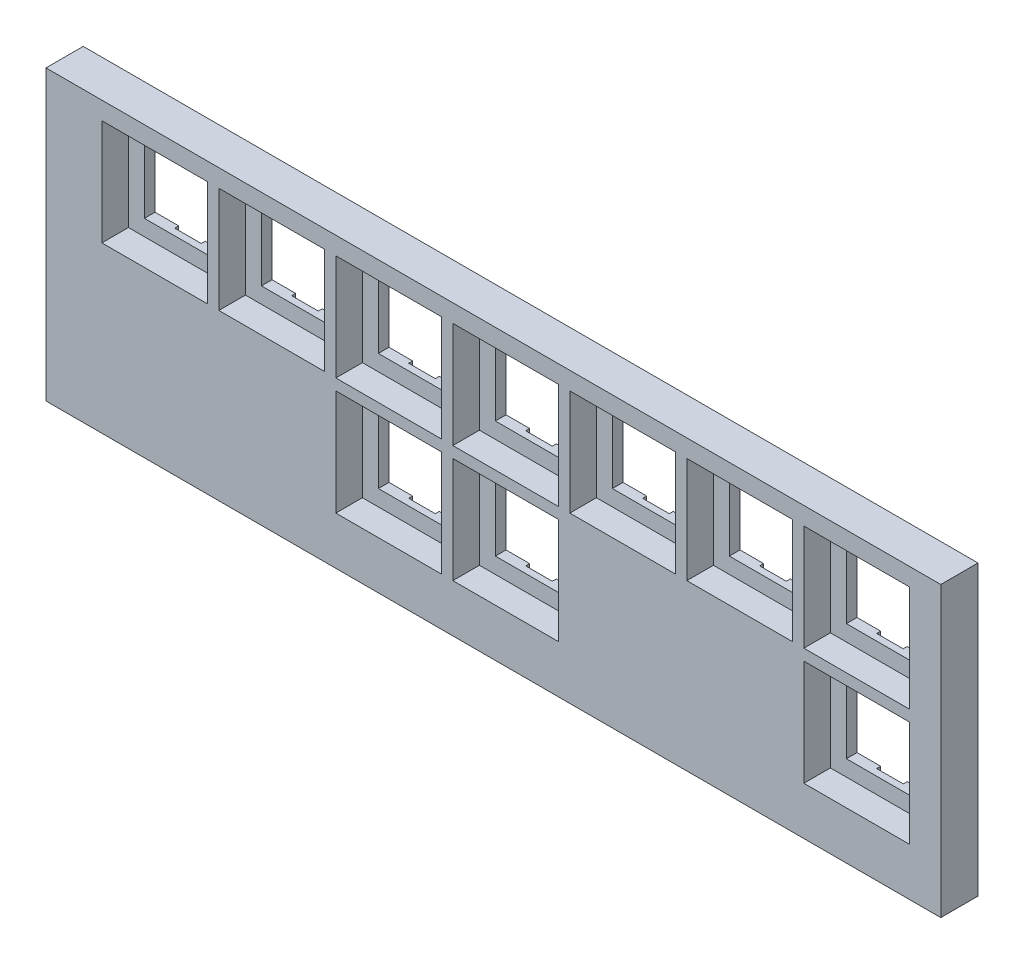
from build123d import *

# Parameters (mm, degrees)
SKETCH6_W                 = 168.25
SKETCH6_H                 = 54.25
BOSS_EXTRUDE2_DEPTH       = 7
SKETCH7_W                 = 19.9
SKETCH7_H                 = 19.9
CUT_EXTRUDE4_DEPTH        = 5
SKETCH8_W                 = 13.9
SKETCH8_H                 = 13.9
CUT_EXTRUDE5_DEPTH        = 4
SKETCH9_W                 = 5
SKETCH9_H                 = 0.75
CUT_EXTRUDE6_DEPTH        = 1
LPATTERN1_COUNT           = 7
LPATTERN1_PITCH           = 22
LPATTERN1_COUNT_DIR2      = 2
LPATTERN1_PITCH_DIR2      = 22
LPATTERN1_COPY_1_SKETCH_W = 5
LPATTERN1_COPY_1_SKETCH_H = 0.75
LPATTERN1_COPY_1_DEPTH    = 1
LPATTERN1_COPY_2_SKETCH_W = 5
LPATTERN1_COPY_2_SKETCH_H = 0.75
LPATTERN1_COPY_2_DEPTH    = 1
LPATTERN1_COPY_3_SKETCH_W = 5
LPATTERN1_COPY_3_SKETCH_H = 0.75
LPATTERN1_COPY_3_DEPTH    = 1
LPATTERN1_COPY_4_SKETCH_W = 5
LPATTERN1_COPY_4_SKETCH_H = 0.75
LPATTERN1_COPY_4_DEPTH    = 1
LPATTERN1_COPY_5_SKETCH_W = 5
LPATTERN1_COPY_5_SKETCH_H = 0.75
LPATTERN1_COPY_5_DEPTH    = 1
LPATTERN1_COPY_6_SKETCH_W = 5
LPATTERN1_COPY_6_SKETCH_H = 0.75
LPATTERN1_COPY_6_DEPTH    = 1
LPATTERN1_COPY_7_SKETCH_W = 5
LPATTERN1_COPY_7_SKETCH_H = 0.75
LPATTERN1_COPY_7_DEPTH    = 1
LPATTERN1_COPY_8_SKETCH_W = 5
LPATTERN1_COPY_8_SKETCH_H = 0.75
LPATTERN1_COPY_8_DEPTH    = 1
LPATTERN1_COPY_9_SKETCH_W = 5
LPATTERN1_COPY_9_SKETCH_H = 0.75
LPATTERN1_COPY_9_DEPTH    = 1


with BuildPart() as part:
    # Sketch6 → Boss-Extrude2 (new body)
    with BuildSketch(Plane.XY):
        with Locations((84.125, 27.125)):
            Rectangle(SKETCH6_W, SKETCH6_H)
    extrude(amount=BOSS_EXTRUDE2_DEPTH)

    # Sketch7 → Cut-Extrude4 (cut)
    with BuildSketch(Plane.XY.offset(7)):
        with Locations((20.45, 40.95)):
            Rectangle(SKETCH7_W, SKETCH7_H)
    cut_extrude4 = extrude(amount=-CUT_EXTRUDE4_DEPTH, mode=Mode.SUBTRACT)

    # Sketch8 → Cut-Extrude5 (cut)
    with BuildSketch(Plane.XY.offset(2)):
        with Locations((20.45, 40.95)):
            Rectangle(SKETCH8_W, SKETCH8_H)
    cut_extrude5 = extrude(amount=-CUT_EXTRUDE5_DEPTH, mode=Mode.SUBTRACT)

    # Sketch9 → Cut-Extrude6 (cut)
    with BuildSketch(Plane(origin=(0, 47.9, 0), x_dir=(-1, 0, 0), z_dir=(0, -1, 0))):
        with Locations((-20.45, -0.375)):
            Rectangle(SKETCH9_W, SKETCH9_H)
    cut_extrude6 = extrude(amount=-CUT_EXTRUDE6_DEPTH, mode=Mode.SUBTRACT)

    # Mirror2: Cut-Extrude6 across plane
    add(cut_extrude6.mirror(Plane(origin=(0, 40.95, 0), x_dir=(0, 0, 1), z_dir=(0, -1, 0))), mode=Mode.SUBTRACT)

    # LPattern1: Cut-Extrude4, Cut-Extrude5, Cut-Extrude6 7 × 2, 4 skipped
    with Locations(*[(i * LPATTERN1_PITCH, -j * LPATTERN1_PITCH_DIR2, 0) for i in range(LPATTERN1_COUNT) for j in range(LPATTERN1_COUNT_DIR2) if (i, j) not in ((0, 0), (0, 1), (1, 1), (4, 1), (5, 1))]):
        add(cut_extrude4, mode=Mode.SUBTRACT)
        add(cut_extrude5, mode=Mode.SUBTRACT)
        add(cut_extrude6, mode=Mode.SUBTRACT)

    # LPattern1 copy 1 sketch → LPattern1 copy 1 (cut)
    with BuildSketch(Plane(origin=(22, 34, 0), x_dir=(-1, 0, 0), z_dir=(0, 1, 0))):
        with Locations((-20.45, 0.375)):
            Rectangle(LPATTERN1_COPY_1_SKETCH_W, LPATTERN1_COPY_1_SKETCH_H)
    extrude(amount=-LPATTERN1_COPY_1_DEPTH, mode=Mode.SUBTRACT)

    # LPattern1 copy 2 sketch → LPattern1 copy 2 (cut)
    with BuildSketch(Plane(origin=(44, 34, 0), x_dir=(-1, 0, 0), z_dir=(0, 1, 0))):
        with Locations((-20.45, 0.375)):
            Rectangle(LPATTERN1_COPY_2_SKETCH_W, LPATTERN1_COPY_2_SKETCH_H)
    extrude(amount=-LPATTERN1_COPY_2_DEPTH, mode=Mode.SUBTRACT)

    # LPattern1 copy 3 sketch → LPattern1 copy 3 (cut)
    with BuildSketch(Plane(origin=(44, 12, 0), x_dir=(-1, 0, 0), z_dir=(0, 1, 0))):
        with Locations((-20.45, 0.375)):
            Rectangle(LPATTERN1_COPY_3_SKETCH_W, LPATTERN1_COPY_3_SKETCH_H)
    extrude(amount=-LPATTERN1_COPY_3_DEPTH, mode=Mode.SUBTRACT)

    # LPattern1 copy 4 sketch → LPattern1 copy 4 (cut)
    with BuildSketch(Plane(origin=(66, 34, 0), x_dir=(-1, 0, 0), z_dir=(0, 1, 0))):
        with Locations((-20.45, 0.375)):
            Rectangle(LPATTERN1_COPY_4_SKETCH_W, LPATTERN1_COPY_4_SKETCH_H)
    extrude(amount=-LPATTERN1_COPY_4_DEPTH, mode=Mode.SUBTRACT)

    # LPattern1 copy 5 sketch → LPattern1 copy 5 (cut)
    with BuildSketch(Plane(origin=(66, 12, 0), x_dir=(-1, 0, 0), z_dir=(0, 1, 0))):
        with Locations((-20.45, 0.375)):
            Rectangle(LPATTERN1_COPY_5_SKETCH_W, LPATTERN1_COPY_5_SKETCH_H)
    extrude(amount=-LPATTERN1_COPY_5_DEPTH, mode=Mode.SUBTRACT)

    # LPattern1 copy 6 sketch → LPattern1 copy 6 (cut)
    with BuildSketch(Plane(origin=(88, 34, 0), x_dir=(-1, 0, 0), z_dir=(0, 1, 0))):
        with Locations((-20.45, 0.375)):
            Rectangle(LPATTERN1_COPY_6_SKETCH_W, LPATTERN1_COPY_6_SKETCH_H)
    extrude(amount=-LPATTERN1_COPY_6_DEPTH, mode=Mode.SUBTRACT)

    # LPattern1 copy 7 sketch → LPattern1 copy 7 (cut)
    with BuildSketch(Plane(origin=(110, 34, 0), x_dir=(-1, 0, 0), z_dir=(0, 1, 0))):
        with Locations((-20.45, 0.375)):
            Rectangle(LPATTERN1_COPY_7_SKETCH_W, LPATTERN1_COPY_7_SKETCH_H)
    extrude(amount=-LPATTERN1_COPY_7_DEPTH, mode=Mode.SUBTRACT)

    # LPattern1 copy 8 sketch → LPattern1 copy 8 (cut)
    with BuildSketch(Plane(origin=(132, 34, 0), x_dir=(-1, 0, 0), z_dir=(0, 1, 0))):
        with Locations((-20.45, 0.375)):
            Rectangle(LPATTERN1_COPY_8_SKETCH_W, LPATTERN1_COPY_8_SKETCH_H)
    extrude(amount=-LPATTERN1_COPY_8_DEPTH, mode=Mode.SUBTRACT)

    # LPattern1 copy 9 sketch → LPattern1 copy 9 (cut)
    with BuildSketch(Plane(origin=(132, 12, 0), x_dir=(-1, 0, 0), z_dir=(0, 1, 0))):
        with Locations((-20.45, 0.375)):
            Rectangle(LPATTERN1_COPY_9_SKETCH_W, LPATTERN1_COPY_9_SKETCH_H)
    extrude(amount=-LPATTERN1_COPY_9_DEPTH, mode=Mode.SUBTRACT)


solid = part.part
